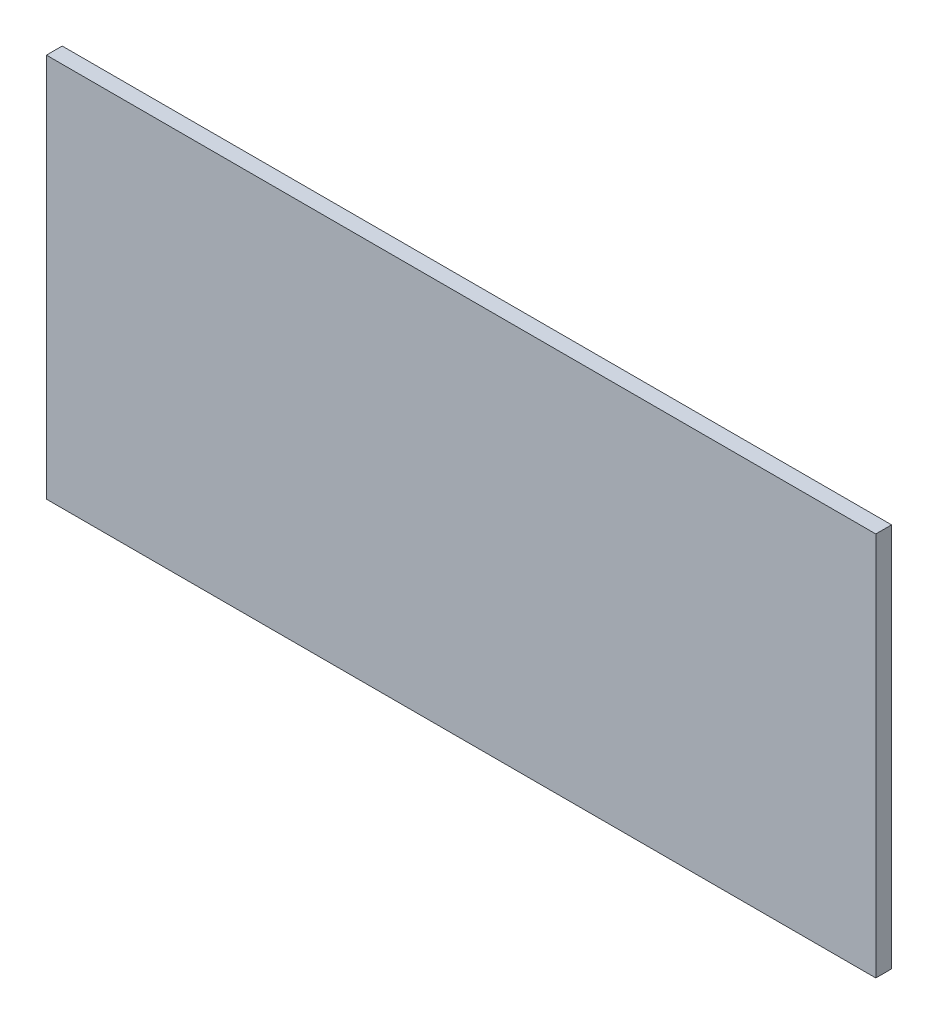
from build123d import *

# Parameters (mm, degrees)
SKETCH1_W           = 1156
SKETCH1_H           = 536
BOSS_EXTRUDE1_DEPTH = 22


with BuildPart() as part:
    # Sketch1 → Boss-Extrude1 (new body)
    with BuildSketch(Plane.XY):
        Rectangle(SKETCH1_W, SKETCH1_H)
    extrude(amount=BOSS_EXTRUDE1_DEPTH)


solid = part.part
